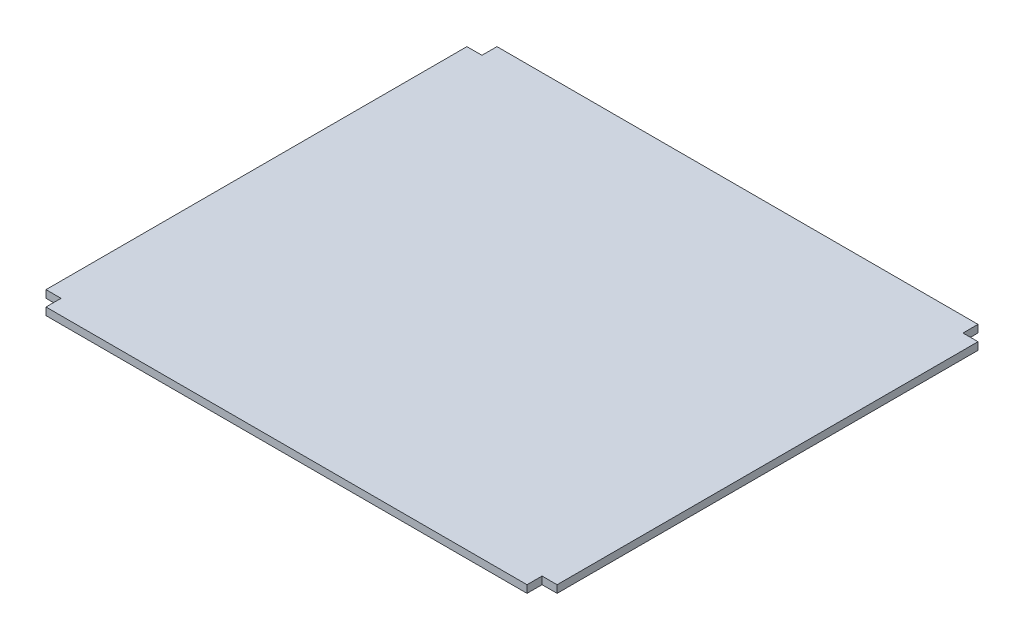
from build123d import *

# Parameters (mm, degrees)
BOSS_EXTRUDE2_DEPTH = 10


with BuildPart() as part:
    # Sketch1 → Boss-Extrude2 (new body)
    with BuildSketch(Plane(origin=(0, 0, 0), x_dir=(1, 0, 0), z_dir=(0, 1, 0))):
        Polygon((320, 300), (-320, 300), (-320, 280), (-340, 280), (-340, -280), (-320, -280), (-320, -300), (320, -300), (320, -280), (340, -280), (340, 280), (320, 280), align=None)
    extrude(amount=BOSS_EXTRUDE2_DEPTH)


solid = part.part
